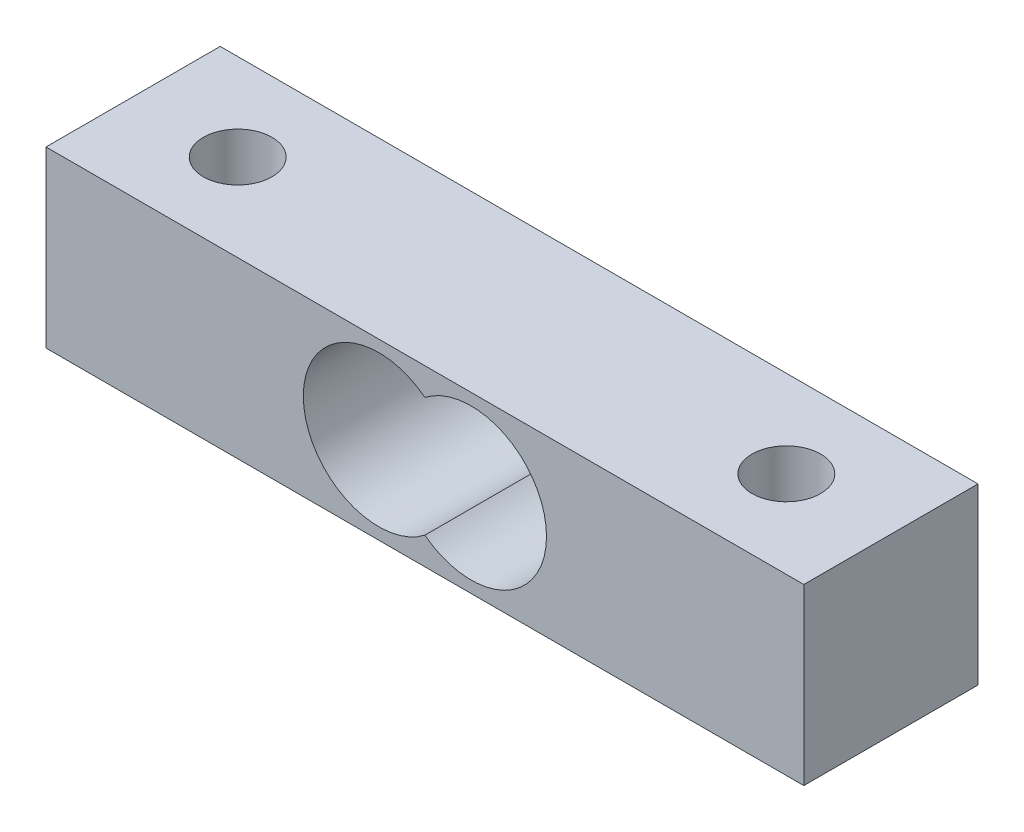
from build123d import *

# Parameters (mm, degrees)
BOSS_EXTRU_2_DEPTH      = 12.7
ESQUISSE3_R             = 2.5
ENL_V_MAT_EXTRU_1_DEPTH = 12.7


with BuildPart() as part:
    # Esquisse1 → Boss.-Extru.2 (new body)
    with BuildSketch(Plane.XY):
        with BuildLine():
            Line((0, 0), (27.625, 0))
            Line((27.625, 0), (27.625, 2))
            ThreePointArc((27.625, 2), (18.759364844, 6.35), (27.625, 10.7))
            Line((27.625, 10.7), (27.625, 12.7))
            Line((27.625, 12.7), (0, 12.7))
            Line((0, 12.7), (0, 0))
        make_face()
    boss_extru_2 = extrude(amount=BOSS_EXTRU_2_DEPTH)

    # Esquisse3 → Enlèv. mat.-Extru.1 (cut)
    with BuildSketch(Plane(origin=(0, 12.7, 0), x_dir=(1, 0, 0), z_dir=(0, 1, 0))):
        with Locations((7.625, -6.35)):
            Circle(ESQUISSE3_R)
    enl_v_mat_extru_1 = extrude(amount=-ENL_V_MAT_EXTRU_1_DEPTH, mode=Mode.SUBTRACT)

    # Symétrie1: Boss.-Extru.2, Enlèv. mat.-Extru.1 across plane
    add(boss_extru_2.mirror(Plane(origin=(27.625, 12.7, 12.7), x_dir=(0, 0, 1), z_dir=(-1, 0, 0))))
    add(enl_v_mat_extru_1.mirror(Plane(origin=(27.625, 12.7, 12.7), x_dir=(0, 0, 1), z_dir=(-1, 0, 0))), mode=Mode.SUBTRACT)


solid = part.part
